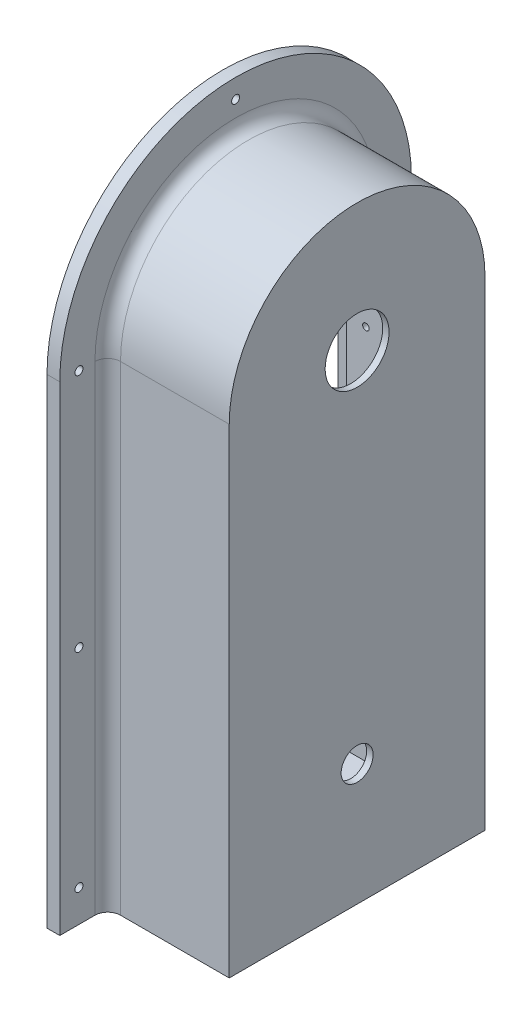
from build123d import *

# Parameters (mm, degrees)
SKETCH_1_W                    = 4
SKETCH_1_H                    = 55
REVOLVE_1_ANGLE               = 180
SKETCH_2_W                    = 4
SKETCH_2_H                    = 110
EXTRUDE_1_DEPTH               = 150
EXTRUDE_2_DEPTH               = 38
CUT_EXTRUDE_1_DEPTH           = 40
SKETCH_5_W                    = 36.5
SKETCH_5_H                    = 54.5
EXTRUDE_3_DEPTH               = 17
SKETCH_6_W                    = 31.5
SKETCH_6_H                    = 49.5
CUT_EXTRUDE_2_DEPTH           = 17
HOLE_WIZARD_20_0_20_1_D       = 20
HOLE_WIZARD_20_0_20_1_DEPTH   = 2
HOLE_WIZARD_10_0_10_1_D       = 10
HOLE_WIZARD_10_0_10_1_DEPTH   = 2
HOLE_WIZARD_2_5_2_5_1_D       = 2.5
HOLE_WIZARD_2_5_2_5_1_DEPTH   = 4
HOLE_WIZARD_2_05_2_05_1_D     = 2.05
HOLE_WIZARD_2_05_2_05_1_DEPTH = 2.5
HOLE_WIZARD_2_05_2_05_2_D     = 2.05
HOLE_WIZARD_2_05_2_05_2_DEPTH = 2.5
HOLE_WIZARD_2_05_2_05_3_D     = 2.05
HOLE_WIZARD_2_05_2_05_3_DEPTH = 2.5
HOLE_WIZARD_2_05_2_05_4_D     = 2.05
HOLE_WIZARD_2_05_2_05_4_DEPTH = 2.5
FILLET_1_R                    = 4


with BuildPart() as part:
    # 스케치1 → 회전1 (revolve)
    with BuildSketch(Plane.XZ.offset(-35.25)):
        with Locations((-21, -41.75)):
            Rectangle(SKETCH_1_W, SKETCH_1_H)
    revolve(axis=Axis((-18.999896922, 35.25, -14.25), (1, 0, 0)), revolution_arc=REVOLVE_1_ANGLE)

    # 스케치2 → 보스-돌출1 (add)
    with BuildSketch(Plane.XZ.offset(-35.25)):
        with Locations((-21, -14.25)):
            Rectangle(SKETCH_2_W, SKETCH_2_H)
    extrude(amount=EXTRUDE_1_DEPTH)

    # 스케치3 → 보스-돌출2 (add)
    with BuildSketch(Plane(origin=(-19, 0, 0), x_dir=(0, 0, -1), z_dir=(1, 0, 0))):
        with BuildLine():
            Line((-25.75, -114.75), (-25.75, 35.25))
            ThreePointArc((-25.75, 35.25), (14.25, 75.25), (54.25, 35.25))
            Line((54.25, 35.25), (54.25, -114.75))
            Line((54.25, -114.75), (-25.75, -114.75))
        make_face()
    extrude(amount=EXTRUDE_2_DEPTH)

    # 스케치4 → 컷-돌출1 (cut)
    with BuildSketch(Plane.ZY.offset(23)):
        with BuildLine():
            Line((-50.25, -110.75), (21.75, -110.75))
            Line((21.75, -110.75), (21.75, 35.25))
            ThreePointArc((21.75, 35.25), (-14.25, 71.25), (-50.25, 35.25))
            Line((-50.25, 35.25), (-50.25, -110.75))
        make_face()
    extrude(amount=-CUT_EXTRUDE_1_DEPTH, mode=Mode.SUBTRACT)

    # 스케치5 → 보스-돌출3 (add)
    with BuildSketch(Plane.ZY.offset(-17)):
        with Locations((-14.25, 23.25)):
            Rectangle(SKETCH_5_W, SKETCH_5_H)
    extrude(amount=EXTRUDE_3_DEPTH)

    # 스케치6 → 컷-돌출2 (cut)
    with BuildSketch(Plane.ZY):
        with Locations((-14.25, 23.25)):
            Rectangle(SKETCH_6_W, SKETCH_6_H)
    extrude(amount=-CUT_EXTRUDE_2_DEPTH, mode=Mode.SUBTRACT)

    # Ø20.0 (20) 지름 구멍1
    with Locations(Plane.ZY.offset(-17)):
        with Locations((-14.25, 35.25)):
            Hole(HOLE_WIZARD_20_0_20_1_D / 2, depth=HOLE_WIZARD_20_0_20_1_DEPTH)

    # Ø10.0 (10) 지름 구멍1
    with Locations(Plane.ZY.offset(-17)):
        with Locations((-14.25, -76.75)):
            Hole(HOLE_WIZARD_10_0_10_1_D / 2, depth=HOLE_WIZARD_10_0_10_1_DEPTH)

    # Ø2.5 (2.5) 지름 구멍1
    with Locations(Plane(origin=(-19, 0, 0), x_dir=(0, 0, -1), z_dir=(1, 0, 0))):
        with Locations((-34.75, -104.75), (63.25, -104.75), (63.25, -39.75), (63.25, 35.25), (-34.75, 35.25), (-34.75, -39.75), (14.25, 84.25)):
            Hole(HOLE_WIZARD_2_5_2_5_1_D / 2, depth=HOLE_WIZARD_2_5_2_5_1_DEPTH)

    # Ø2.05 (2.05) 지름 구멍1
    with Locations(Plane(origin=(0, -1.5, 0), x_dir=(1, 0, 0), z_dir=(0, 1, 0))):
        with Locations((6, 6.25), (6, 22.25)):
            Hole(HOLE_WIZARD_2_05_2_05_1_D / 2, depth=HOLE_WIZARD_2_05_2_05_1_DEPTH)

    # Ø2.05 (2.05) 지름 구멍2
    with Locations(Plane(origin=(0, 0, 1.5), x_dir=(-1, 0, 0), z_dir=(0, 0, -1))):
        with Locations((-6, 27.25), (-6, 3.25)):
            Hole(HOLE_WIZARD_2_05_2_05_2_D / 2, depth=HOLE_WIZARD_2_05_2_05_2_DEPTH)

    # Ø2.05 (2.05) 지름 구멍3
    with Locations(Plane(origin=(0, 48, 0), x_dir=(-1, 0, 0), z_dir=(0, -1, 0))):
        with Locations((-6, 6.25), (-6, 22.25)):
            Hole(HOLE_WIZARD_2_05_2_05_3_D / 2, depth=HOLE_WIZARD_2_05_2_05_3_DEPTH)

    # Ø2.05 (2.05) 지름 구멍4
    with Locations(Plane.XY.offset(-30)):
        with Locations((6, 27.25), (6, 3.25)):
            Hole(HOLE_WIZARD_2_05_2_05_4_D / 2, depth=HOLE_WIZARD_2_05_2_05_4_DEPTH)

    # 필렛1
    fillet_1_edges = [part.edges().sort_by_distance(p)[0] for p in [
        (-19, -39.75, -54.25),
        (-19, 75.25, -14.25),
        (-19, -39.75, 25.75),
    ]]
    fillet(fillet_1_edges, radius=FILLET_1_R)


solid = part.part
